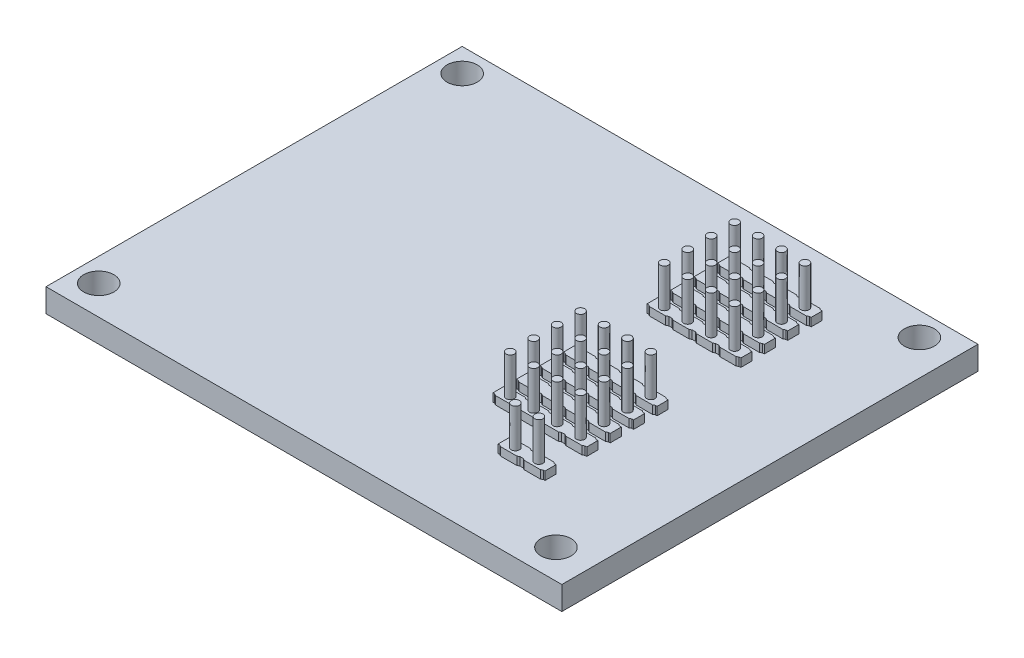
from build123d import *

# Parameters (mm, degrees)
SKETCH1_W                  = 55.88
SKETCH1_H                  = 45.085
BOSS_EXTRUDE1_DEPTH        = 2.54
F_4_CLEARANCE_HOLE1_D      = 3.2639
F_4_CLEARANCE_HOLE1_DEPTH  = 2.54
SKETCH4_R                  = 0.4445
CUT_EXTRUDE1_DEPTH         = 3.54
LPATTERN1_COUNT            = 4
LPATTERN1_PITCH            = 2.54
LPATTERN1_COUNT_DIR2       = 4
LPATTERN1_PITCH_DIR2       = 2.54
SKETCH5_R                  = 0.4445
CUT_EXTRUDE2_DEPTH         = 3.54
SKETCH6_W                  = 1.758187998
SKETCH6_H                  = 1.44539188
SKETCH6_R                  = 0.4445
BOSS_EXTRUDE2_DEPTH        = 0.889
LPATTERN3_COUNT            = 4
LPATTERN3_PITCH            = 2.54
LPATTERN3_COUNT_DIR2       = 4
LPATTERN3_PITCH_DIR2       = 2.54
LPATTERN4_COUNT            = 2
LPATTERN4_PITCH            = 16.6878
LPATTERN5_COPY_1_SKETCH_W  = 1.758187998
LPATTERN5_COPY_1_SKETCH_H  = 1.44539188
LPATTERN5_COPY_1_SKETCH_R  = 0.4445
LPATTERN5_COPY_1_DEPTH     = 0.889
LPATTERN5_COPY_2_SKETCH_W  = 1.758187998
LPATTERN5_COPY_2_SKETCH_H  = 1.44539188
LPATTERN5_COPY_2_SKETCH_R  = 0.4445
LPATTERN5_COPY_2_DEPTH     = 0.889
LPATTERN5_COPY_3_SKETCH_W  = 1.758187998
LPATTERN5_COPY_3_SKETCH_H  = 1.44539188
LPATTERN5_COPY_3_SKETCH_R  = 0.4445
LPATTERN5_COPY_3_DEPTH     = 0.889
LPATTERN5_COPY_4_SKETCH_W  = 1.758187998
LPATTERN5_COPY_4_SKETCH_H  = 1.44539188
LPATTERN5_COPY_4_SKETCH_R  = 0.4445
LPATTERN5_COPY_4_DEPTH     = 0.889
LPATTERN5_COPY_5_SKETCH_W  = 1.758187998
LPATTERN5_COPY_5_SKETCH_H  = 1.44539188
LPATTERN5_COPY_5_SKETCH_R  = 0.4445
LPATTERN5_COPY_5_DEPTH     = 0.889
LPATTERN5_COPY_6_SKETCH_W  = 1.758187998
LPATTERN5_COPY_6_SKETCH_H  = 1.44539188
LPATTERN5_COPY_6_SKETCH_R  = 0.4445
LPATTERN5_COPY_6_DEPTH     = 0.889
LPATTERN5_COPY_7_SKETCH_W  = 1.758187998
LPATTERN5_COPY_7_SKETCH_H  = 1.44539188
LPATTERN5_COPY_7_SKETCH_R  = 0.4445
LPATTERN5_COPY_7_DEPTH     = 0.889
LPATTERN5_COPY_8_SKETCH_W  = 1.758187998
LPATTERN5_COPY_8_SKETCH_H  = 1.44539188
LPATTERN5_COPY_8_SKETCH_R  = 0.4445
LPATTERN5_COPY_8_DEPTH     = 0.889
LPATTERN5_COPY_9_SKETCH_W  = 1.758187998
LPATTERN5_COPY_9_SKETCH_H  = 1.44539188
LPATTERN5_COPY_9_SKETCH_R  = 0.4445
LPATTERN5_COPY_9_DEPTH     = 0.889
LPATTERN5_COPY_10_SKETCH_W = 1.758187998
LPATTERN5_COPY_10_SKETCH_H = 1.44539188
LPATTERN5_COPY_10_SKETCH_R = 0.4445
LPATTERN5_COPY_10_DEPTH    = 0.889
LPATTERN5_COPY_11_SKETCH_W = 1.758187998
LPATTERN5_COPY_11_SKETCH_H = 1.44539188
LPATTERN5_COPY_11_SKETCH_R = 0.4445
LPATTERN5_COPY_11_DEPTH    = 0.889
LPATTERN5_COPY_12_SKETCH_W = 1.758187998
LPATTERN5_COPY_12_SKETCH_H = 1.44539188
LPATTERN5_COPY_12_SKETCH_R = 0.4445
LPATTERN5_COPY_12_DEPTH    = 0.889
LPATTERN5_COPY_13_SKETCH_W = 1.758187998
LPATTERN5_COPY_13_SKETCH_H = 1.44539188
LPATTERN5_COPY_13_SKETCH_R = 0.4445
LPATTERN5_COPY_13_DEPTH    = 0.889
LPATTERN5_COPY_14_SKETCH_W = 1.758187998
LPATTERN5_COPY_14_SKETCH_H = 1.44539188
LPATTERN5_COPY_14_SKETCH_R = 0.4445
LPATTERN5_COPY_14_DEPTH    = 0.889
LPATTERN5_COPY_15_SKETCH_W = 1.758187998
LPATTERN5_COPY_15_SKETCH_H = 1.44539188
LPATTERN5_COPY_15_SKETCH_R = 0.4445
LPATTERN5_COPY_15_DEPTH    = 0.889
LPATTERN5_COPY_16_SKETCH_W = 1.758187998
LPATTERN5_COPY_16_SKETCH_H = 1.44539188
LPATTERN5_COPY_16_SKETCH_R = 0.4445
LPATTERN5_COPY_16_DEPTH    = 0.889
LPATTERN5_COPY_17_SKETCH_W = 1.758187998
LPATTERN5_COPY_17_SKETCH_H = 1.44539188
LPATTERN5_COPY_17_SKETCH_R = 0.4445
LPATTERN5_COPY_17_DEPTH    = 0.889
LPATTERN5_COPY_18_SKETCH_W = 1.758187998
LPATTERN5_COPY_18_SKETCH_H = 1.44539188
LPATTERN5_COPY_18_SKETCH_R = 0.4445
LPATTERN5_COPY_18_DEPTH    = 0.889
LPATTERN5_COPY_19_SKETCH_W = 1.758187998
LPATTERN5_COPY_19_SKETCH_H = 1.44539188
LPATTERN5_COPY_19_SKETCH_R = 0.4445
LPATTERN5_COPY_19_DEPTH    = 0.889
LPATTERN5_COPY_20_SKETCH_W = 1.758187998
LPATTERN5_COPY_20_SKETCH_H = 1.44539188
LPATTERN5_COPY_20_SKETCH_R = 0.4445
LPATTERN5_COPY_20_DEPTH    = 0.889
LPATTERN5_COPY_21_SKETCH_W = 1.758187998
LPATTERN5_COPY_21_SKETCH_H = 1.44539188
LPATTERN5_COPY_21_SKETCH_R = 0.4445
LPATTERN5_COPY_21_DEPTH    = 0.889
LPATTERN5_COPY_22_SKETCH_W = 1.758187998
LPATTERN5_COPY_22_SKETCH_H = 1.44539188
LPATTERN5_COPY_22_SKETCH_R = 0.4445
LPATTERN5_COPY_22_DEPTH    = 0.889
LPATTERN5_COPY_23_SKETCH_W = 1.758187998
LPATTERN5_COPY_23_SKETCH_H = 1.44539188
LPATTERN5_COPY_23_SKETCH_R = 0.4445
LPATTERN5_COPY_23_DEPTH    = 0.889
LPATTERN5_COPY_24_SKETCH_W = 1.758187998
LPATTERN5_COPY_24_SKETCH_H = 1.44539188
LPATTERN5_COPY_24_SKETCH_R = 0.4445
LPATTERN5_COPY_24_DEPTH    = 0.889
LPATTERN5_COPY_25_SKETCH_W = 1.758187998
LPATTERN5_COPY_25_SKETCH_H = 1.44539188
LPATTERN5_COPY_25_SKETCH_R = 0.4445
LPATTERN5_COPY_25_DEPTH    = 0.889
LPATTERN5_COPY_26_SKETCH_W = 1.758187998
LPATTERN5_COPY_26_SKETCH_H = 1.44539188
LPATTERN5_COPY_26_SKETCH_R = 0.4445
LPATTERN5_COPY_26_DEPTH    = 0.889
LPATTERN5_COPY_27_SKETCH_W = 1.758187998
LPATTERN5_COPY_27_SKETCH_H = 1.44539188
LPATTERN5_COPY_27_SKETCH_R = 0.4445
LPATTERN5_COPY_27_DEPTH    = 0.889
LPATTERN5_COPY_28_SKETCH_W = 1.758187998
LPATTERN5_COPY_28_SKETCH_H = 1.44539188
LPATTERN5_COPY_28_SKETCH_R = 0.4445
LPATTERN5_COPY_28_DEPTH    = 0.889
LPATTERN5_COPY_29_SKETCH_W = 1.758187998
LPATTERN5_COPY_29_SKETCH_H = 1.44539188
LPATTERN5_COPY_29_SKETCH_R = 0.4445
LPATTERN5_COPY_29_DEPTH    = 0.889
LPATTERN5_COPY_30_SKETCH_W = 1.758187998
LPATTERN5_COPY_30_SKETCH_H = 1.44539188
LPATTERN5_COPY_30_SKETCH_R = 0.4445
LPATTERN5_COPY_30_DEPTH    = 0.889
LPATTERN6_COUNT            = 2
LPATTERN6_PITCH            = 28.829
LPATTERN7_COPY_1_SKETCH_W  = 1.758187998
LPATTERN7_COPY_1_SKETCH_H  = 1.44539188
LPATTERN7_COPY_1_SKETCH_R  = 0.4445
LPATTERN7_COPY_1_DEPTH     = 0.889
LPATTERN7_COPY_2_SKETCH_W  = 1.758187998
LPATTERN7_COPY_2_SKETCH_H  = 1.44539188
LPATTERN7_COPY_2_SKETCH_R  = 0.4445
LPATTERN7_COPY_2_DEPTH     = 0.889
SKETCH7_R                  = 0.4445
BOSS_EXTRUDE3_DEPTH        = 5.08
BOSS_EXTRUDE3_DEPTH_BACK   = 5.08


with BuildPart() as part:
    # Sketch1 → Boss-Extrude1 (new body)
    with BuildSketch(Plane(origin=(0, 0, 0), x_dir=(1, 0, 0), z_dir=(0, 1, 0))):
        Rectangle(SKETCH1_W, SKETCH1_H)
    extrude(amount=BOSS_EXTRUDE1_DEPTH)

    # #4 Clearance Hole1
    with Locations(Plane(origin=(0, 2.54, 0), x_dir=(1, 0, 0), z_dir=(0, 1, 0))):
        with Locations((-25.4, -19.3675), (-25.4, 20.0025), (24.13, 20.0025), (24.13, -19.3675)):
            Hole(F_4_CLEARANCE_HOLE1_D / 2, depth=F_4_CLEARANCE_HOLE1_DEPTH)

    # Sketch4 → Cut-Extrude1 (cut, through all)
    with BuildSketch(Plane(origin=(0, 2.54, 0), x_dir=(1, 0, 0), z_dir=(0, 1, 0))):
        with Locations((16.002, 15.7353)):
            Circle(SKETCH4_R)
        with Locations((16.002, -0.9525)):
            Circle(SKETCH4_R)
    cut_extrude1 = extrude(amount=-CUT_EXTRUDE1_DEPTH, mode=Mode.SUBTRACT)

    # LPattern1: Cut-Extrude1 4 × 4
    with Locations(*[(-j * LPATTERN1_PITCH_DIR2, 0, i * LPATTERN1_PITCH) for i in range(LPATTERN1_COUNT) for j in range(LPATTERN1_COUNT_DIR2) if (i, j) != (0, 0)]):
        add(cut_extrude1, mode=Mode.SUBTRACT)

    # Sketch5 → Cut-Extrude2 (cut, through all)
    with BuildSketch(Plane(origin=(0, 2.54, 0), x_dir=(1, 0, 0), z_dir=(0, 1, 0))):
        with Locations((16.002, -13.084491253)):
            Circle(SKETCH5_R)
        with Locations((13.462, -13.084491253)):
            Circle(SKETCH5_R)
    extrude(amount=-CUT_EXTRUDE2_DEPTH, mode=Mode.SUBTRACT)

    # Sketch6 → Boss-Extrude2 (add)
    with BuildSketch(Plane(origin=(0, 2.54, 0), x_dir=(1, 0, 0), z_dir=(0, 1, 0))):
        Polygon((17.085979817, 16.334198582), (17.272, 16.334198582), (17.272, 15.136401418), (17.085979817, 15.136401418), (16.881093999, 15.01260406), (16.881093999, 16.45799594), align=None)
        with Locations((16.002, 15.7353)):
            Rectangle(SKETCH6_W, SKETCH6_H)
        with Locations((16.002, 15.7353)):
            Circle(SKETCH6_R, mode=Mode.SUBTRACT)
        Polygon((14.732, 15.136401418), (14.918020183, 15.136401418), (15.122906001, 15.01260406), (15.122906001, 16.45799594), (14.918020183, 16.334198582), (14.732, 16.334198582), align=None)
    boss_extrude2 = extrude(amount=BOSS_EXTRUDE2_DEPTH)

    # LPattern3: Boss-Extrude2 4 × 4
    with Locations(*[(-j * LPATTERN3_PITCH_DIR2, 0, i * LPATTERN3_PITCH) for i in range(LPATTERN3_COUNT) for j in range(LPATTERN3_COUNT_DIR2) if (i, j) != (0, 0)]):
        add(boss_extrude2)

    # LPattern4: Boss-Extrude2 ×2
    with Locations(*[(0, 0, i * LPATTERN4_PITCH) for i in range(1, LPATTERN4_COUNT)]):
        add(boss_extrude2)

    # LPattern5 copy 1 sketch → LPattern5 copy 1 (add)
    with BuildSketch(Plane(origin=(-2.54, 2.54, 16.6878), x_dir=(1, 0, 0), z_dir=(0, 1, 0))):
        Polygon((17.085979817, 16.334198582), (17.272, 16.334198582), (17.272, 15.136401418), (17.085979817, 15.136401418), (16.881093999, 15.01260406), (16.881093999, 16.45799594), align=None)
        with Locations((16.002, 15.7353)):
            Rectangle(LPATTERN5_COPY_1_SKETCH_W, LPATTERN5_COPY_1_SKETCH_H)
        with Locations((16.002, 15.7353)):
            Circle(LPATTERN5_COPY_1_SKETCH_R, mode=Mode.SUBTRACT)
        Polygon((14.732, 15.136401418), (14.918020183, 15.136401418), (15.122906001, 15.01260406), (15.122906001, 16.45799594), (14.918020183, 16.334198582), (14.732, 16.334198582), align=None)
    extrude(amount=LPATTERN5_COPY_1_DEPTH)

    # LPattern5 copy 2 sketch → LPattern5 copy 2 (add)
    with BuildSketch(Plane(origin=(-5.08, 2.54, 16.6878), x_dir=(1, 0, 0), z_dir=(0, 1, 0))):
        Polygon((17.085979817, 16.334198582), (17.272, 16.334198582), (17.272, 15.136401418), (17.085979817, 15.136401418), (16.881093999, 15.01260406), (16.881093999, 16.45799594), align=None)
        with Locations((16.002, 15.7353)):
            Rectangle(LPATTERN5_COPY_2_SKETCH_W, LPATTERN5_COPY_2_SKETCH_H)
        with Locations((16.002, 15.7353)):
            Circle(LPATTERN5_COPY_2_SKETCH_R, mode=Mode.SUBTRACT)
        Polygon((14.732, 15.136401418), (14.918020183, 15.136401418), (15.122906001, 15.01260406), (15.122906001, 16.45799594), (14.918020183, 16.334198582), (14.732, 16.334198582), align=None)
    extrude(amount=LPATTERN5_COPY_2_DEPTH)

    # LPattern5 copy 3 sketch → LPattern5 copy 3 (add)
    with BuildSketch(Plane(origin=(-7.62, 2.54, 16.6878), x_dir=(1, 0, 0), z_dir=(0, 1, 0))):
        Polygon((17.085979817, 16.334198582), (17.272, 16.334198582), (17.272, 15.136401418), (17.085979817, 15.136401418), (16.881093999, 15.01260406), (16.881093999, 16.45799594), align=None)
        with Locations((16.002, 15.7353)):
            Rectangle(LPATTERN5_COPY_3_SKETCH_W, LPATTERN5_COPY_3_SKETCH_H)
        with Locations((16.002, 15.7353)):
            Circle(LPATTERN5_COPY_3_SKETCH_R, mode=Mode.SUBTRACT)
        Polygon((14.732, 15.136401418), (14.918020183, 15.136401418), (15.122906001, 15.01260406), (15.122906001, 16.45799594), (14.918020183, 16.334198582), (14.732, 16.334198582), align=None)
    extrude(amount=LPATTERN5_COPY_3_DEPTH)

    # LPattern5 copy 4 sketch → LPattern5 copy 4 (add)
    with BuildSketch(Plane(origin=(0, 2.54, 19.2278), x_dir=(1, 0, 0), z_dir=(0, 1, 0))):
        Polygon((17.085979817, 16.334198582), (17.272, 16.334198582), (17.272, 15.136401418), (17.085979817, 15.136401418), (16.881093999, 15.01260406), (16.881093999, 16.45799594), align=None)
        with Locations((16.002, 15.7353)):
            Rectangle(LPATTERN5_COPY_4_SKETCH_W, LPATTERN5_COPY_4_SKETCH_H)
        with Locations((16.002, 15.7353)):
            Circle(LPATTERN5_COPY_4_SKETCH_R, mode=Mode.SUBTRACT)
        Polygon((14.732, 15.136401418), (14.918020183, 15.136401418), (15.122906001, 15.01260406), (15.122906001, 16.45799594), (14.918020183, 16.334198582), (14.732, 16.334198582), align=None)
    extrude(amount=LPATTERN5_COPY_4_DEPTH)

    # LPattern5 copy 5 sketch → LPattern5 copy 5 (add)
    with BuildSketch(Plane(origin=(-2.54, 2.54, 19.2278), x_dir=(1, 0, 0), z_dir=(0, 1, 0))):
        Polygon((17.085979817, 16.334198582), (17.272, 16.334198582), (17.272, 15.136401418), (17.085979817, 15.136401418), (16.881093999, 15.01260406), (16.881093999, 16.45799594), align=None)
        with Locations((16.002, 15.7353)):
            Rectangle(LPATTERN5_COPY_5_SKETCH_W, LPATTERN5_COPY_5_SKETCH_H)
        with Locations((16.002, 15.7353)):
            Circle(LPATTERN5_COPY_5_SKETCH_R, mode=Mode.SUBTRACT)
        Polygon((14.732, 15.136401418), (14.918020183, 15.136401418), (15.122906001, 15.01260406), (15.122906001, 16.45799594), (14.918020183, 16.334198582), (14.732, 16.334198582), align=None)
    extrude(amount=LPATTERN5_COPY_5_DEPTH)

    # LPattern5 copy 6 sketch → LPattern5 copy 6 (add)
    with BuildSketch(Plane(origin=(-5.08, 2.54, 19.2278), x_dir=(1, 0, 0), z_dir=(0, 1, 0))):
        Polygon((17.085979817, 16.334198582), (17.272, 16.334198582), (17.272, 15.136401418), (17.085979817, 15.136401418), (16.881093999, 15.01260406), (16.881093999, 16.45799594), align=None)
        with Locations((16.002, 15.7353)):
            Rectangle(LPATTERN5_COPY_6_SKETCH_W, LPATTERN5_COPY_6_SKETCH_H)
        with Locations((16.002, 15.7353)):
            Circle(LPATTERN5_COPY_6_SKETCH_R, mode=Mode.SUBTRACT)
        Polygon((14.732, 15.136401418), (14.918020183, 15.136401418), (15.122906001, 15.01260406), (15.122906001, 16.45799594), (14.918020183, 16.334198582), (14.732, 16.334198582), align=None)
    extrude(amount=LPATTERN5_COPY_6_DEPTH)

    # LPattern5 copy 7 sketch → LPattern5 copy 7 (add)
    with BuildSketch(Plane(origin=(-7.62, 2.54, 19.2278), x_dir=(1, 0, 0), z_dir=(0, 1, 0))):
        Polygon((17.085979817, 16.334198582), (17.272, 16.334198582), (17.272, 15.136401418), (17.085979817, 15.136401418), (16.881093999, 15.01260406), (16.881093999, 16.45799594), align=None)
        with Locations((16.002, 15.7353)):
            Rectangle(LPATTERN5_COPY_7_SKETCH_W, LPATTERN5_COPY_7_SKETCH_H)
        with Locations((16.002, 15.7353)):
            Circle(LPATTERN5_COPY_7_SKETCH_R, mode=Mode.SUBTRACT)
        Polygon((14.732, 15.136401418), (14.918020183, 15.136401418), (15.122906001, 15.01260406), (15.122906001, 16.45799594), (14.918020183, 16.334198582), (14.732, 16.334198582), align=None)
    extrude(amount=LPATTERN5_COPY_7_DEPTH)

    # LPattern5 copy 8 sketch → LPattern5 copy 8 (add)
    with BuildSketch(Plane(origin=(0, 2.54, 21.7678), x_dir=(1, 0, 0), z_dir=(0, 1, 0))):
        Polygon((17.085979817, 16.334198582), (17.272, 16.334198582), (17.272, 15.136401418), (17.085979817, 15.136401418), (16.881093999, 15.01260406), (16.881093999, 16.45799594), align=None)
        with Locations((16.002, 15.7353)):
            Rectangle(LPATTERN5_COPY_8_SKETCH_W, LPATTERN5_COPY_8_SKETCH_H)
        with Locations((16.002, 15.7353)):
            Circle(LPATTERN5_COPY_8_SKETCH_R, mode=Mode.SUBTRACT)
        Polygon((14.732, 15.136401418), (14.918020183, 15.136401418), (15.122906001, 15.01260406), (15.122906001, 16.45799594), (14.918020183, 16.334198582), (14.732, 16.334198582), align=None)
    extrude(amount=LPATTERN5_COPY_8_DEPTH)

    # LPattern5 copy 9 sketch → LPattern5 copy 9 (add)
    with BuildSketch(Plane(origin=(-2.54, 2.54, 21.7678), x_dir=(1, 0, 0), z_dir=(0, 1, 0))):
        Polygon((17.085979817, 16.334198582), (17.272, 16.334198582), (17.272, 15.136401418), (17.085979817, 15.136401418), (16.881093999, 15.01260406), (16.881093999, 16.45799594), align=None)
        with Locations((16.002, 15.7353)):
            Rectangle(LPATTERN5_COPY_9_SKETCH_W, LPATTERN5_COPY_9_SKETCH_H)
        with Locations((16.002, 15.7353)):
            Circle(LPATTERN5_COPY_9_SKETCH_R, mode=Mode.SUBTRACT)
        Polygon((14.732, 15.136401418), (14.918020183, 15.136401418), (15.122906001, 15.01260406), (15.122906001, 16.45799594), (14.918020183, 16.334198582), (14.732, 16.334198582), align=None)
    extrude(amount=LPATTERN5_COPY_9_DEPTH)

    # LPattern5 copy 10 sketch → LPattern5 copy 10 (add)
    with BuildSketch(Plane(origin=(-5.08, 2.54, 21.7678), x_dir=(1, 0, 0), z_dir=(0, 1, 0))):
        Polygon((17.085979817, 16.334198582), (17.272, 16.334198582), (17.272, 15.136401418), (17.085979817, 15.136401418), (16.881093999, 15.01260406), (16.881093999, 16.45799594), align=None)
        with Locations((16.002, 15.7353)):
            Rectangle(LPATTERN5_COPY_10_SKETCH_W, LPATTERN5_COPY_10_SKETCH_H)
        with Locations((16.002, 15.7353)):
            Circle(LPATTERN5_COPY_10_SKETCH_R, mode=Mode.SUBTRACT)
        Polygon((14.732, 15.136401418), (14.918020183, 15.136401418), (15.122906001, 15.01260406), (15.122906001, 16.45799594), (14.918020183, 16.334198582), (14.732, 16.334198582), align=None)
    extrude(amount=LPATTERN5_COPY_10_DEPTH)

    # LPattern5 copy 11 sketch → LPattern5 copy 11 (add)
    with BuildSketch(Plane(origin=(-7.62, 2.54, 21.7678), x_dir=(1, 0, 0), z_dir=(0, 1, 0))):
        Polygon((17.085979817, 16.334198582), (17.272, 16.334198582), (17.272, 15.136401418), (17.085979817, 15.136401418), (16.881093999, 15.01260406), (16.881093999, 16.45799594), align=None)
        with Locations((16.002, 15.7353)):
            Rectangle(LPATTERN5_COPY_11_SKETCH_W, LPATTERN5_COPY_11_SKETCH_H)
        with Locations((16.002, 15.7353)):
            Circle(LPATTERN5_COPY_11_SKETCH_R, mode=Mode.SUBTRACT)
        Polygon((14.732, 15.136401418), (14.918020183, 15.136401418), (15.122906001, 15.01260406), (15.122906001, 16.45799594), (14.918020183, 16.334198582), (14.732, 16.334198582), align=None)
    extrude(amount=LPATTERN5_COPY_11_DEPTH)

    # LPattern5 copy 12 sketch → LPattern5 copy 12 (add)
    with BuildSketch(Plane(origin=(0, 2.54, 24.3078), x_dir=(1, 0, 0), z_dir=(0, 1, 0))):
        Polygon((17.085979817, 16.334198582), (17.272, 16.334198582), (17.272, 15.136401418), (17.085979817, 15.136401418), (16.881093999, 15.01260406), (16.881093999, 16.45799594), align=None)
        with Locations((16.002, 15.7353)):
            Rectangle(LPATTERN5_COPY_12_SKETCH_W, LPATTERN5_COPY_12_SKETCH_H)
        with Locations((16.002, 15.7353)):
            Circle(LPATTERN5_COPY_12_SKETCH_R, mode=Mode.SUBTRACT)
        Polygon((14.732, 15.136401418), (14.918020183, 15.136401418), (15.122906001, 15.01260406), (15.122906001, 16.45799594), (14.918020183, 16.334198582), (14.732, 16.334198582), align=None)
    extrude(amount=LPATTERN5_COPY_12_DEPTH)

    # LPattern5 copy 13 sketch → LPattern5 copy 13 (add)
    with BuildSketch(Plane(origin=(-2.54, 2.54, 24.3078), x_dir=(1, 0, 0), z_dir=(0, 1, 0))):
        Polygon((17.085979817, 16.334198582), (17.272, 16.334198582), (17.272, 15.136401418), (17.085979817, 15.136401418), (16.881093999, 15.01260406), (16.881093999, 16.45799594), align=None)
        with Locations((16.002, 15.7353)):
            Rectangle(LPATTERN5_COPY_13_SKETCH_W, LPATTERN5_COPY_13_SKETCH_H)
        with Locations((16.002, 15.7353)):
            Circle(LPATTERN5_COPY_13_SKETCH_R, mode=Mode.SUBTRACT)
        Polygon((14.732, 15.136401418), (14.918020183, 15.136401418), (15.122906001, 15.01260406), (15.122906001, 16.45799594), (14.918020183, 16.334198582), (14.732, 16.334198582), align=None)
    extrude(amount=LPATTERN5_COPY_13_DEPTH)

    # LPattern5 copy 14 sketch → LPattern5 copy 14 (add)
    with BuildSketch(Plane(origin=(-5.08, 2.54, 24.3078), x_dir=(1, 0, 0), z_dir=(0, 1, 0))):
        Polygon((17.085979817, 16.334198582), (17.272, 16.334198582), (17.272, 15.136401418), (17.085979817, 15.136401418), (16.881093999, 15.01260406), (16.881093999, 16.45799594), align=None)
        with Locations((16.002, 15.7353)):
            Rectangle(LPATTERN5_COPY_14_SKETCH_W, LPATTERN5_COPY_14_SKETCH_H)
        with Locations((16.002, 15.7353)):
            Circle(LPATTERN5_COPY_14_SKETCH_R, mode=Mode.SUBTRACT)
        Polygon((14.732, 15.136401418), (14.918020183, 15.136401418), (15.122906001, 15.01260406), (15.122906001, 16.45799594), (14.918020183, 16.334198582), (14.732, 16.334198582), align=None)
    extrude(amount=LPATTERN5_COPY_14_DEPTH)

    # LPattern5 copy 15 sketch → LPattern5 copy 15 (add)
    with BuildSketch(Plane(origin=(-7.62, 2.54, 24.3078), x_dir=(1, 0, 0), z_dir=(0, 1, 0))):
        Polygon((17.085979817, 16.334198582), (17.272, 16.334198582), (17.272, 15.136401418), (17.085979817, 15.136401418), (16.881093999, 15.01260406), (16.881093999, 16.45799594), align=None)
        with Locations((16.002, 15.7353)):
            Rectangle(LPATTERN5_COPY_15_SKETCH_W, LPATTERN5_COPY_15_SKETCH_H)
        with Locations((16.002, 15.7353)):
            Circle(LPATTERN5_COPY_15_SKETCH_R, mode=Mode.SUBTRACT)
        Polygon((14.732, 15.136401418), (14.918020183, 15.136401418), (15.122906001, 15.01260406), (15.122906001, 16.45799594), (14.918020183, 16.334198582), (14.732, 16.334198582), align=None)
    extrude(amount=LPATTERN5_COPY_15_DEPTH)

    # LPattern5 copy 16 sketch → LPattern5 copy 16 (add)
    with BuildSketch(Plane(origin=(-2.54, 2.54, 0), x_dir=(1, 0, 0), z_dir=(0, 1, 0))):
        Polygon((17.085979817, 16.334198582), (17.272, 16.334198582), (17.272, 15.136401418), (17.085979817, 15.136401418), (16.881093999, 15.01260406), (16.881093999, 16.45799594), align=None)
        with Locations((16.002, 15.7353)):
            Rectangle(LPATTERN5_COPY_16_SKETCH_W, LPATTERN5_COPY_16_SKETCH_H)
        with Locations((16.002, 15.7353)):
            Circle(LPATTERN5_COPY_16_SKETCH_R, mode=Mode.SUBTRACT)
        Polygon((14.732, 15.136401418), (14.918020183, 15.136401418), (15.122906001, 15.01260406), (15.122906001, 16.45799594), (14.918020183, 16.334198582), (14.732, 16.334198582), align=None)
    extrude(amount=LPATTERN5_COPY_16_DEPTH)

    # LPattern5 copy 17 sketch → LPattern5 copy 17 (add)
    with BuildSketch(Plane(origin=(-5.08, 2.54, 0), x_dir=(1, 0, 0), z_dir=(0, 1, 0))):
        Polygon((17.085979817, 16.334198582), (17.272, 16.334198582), (17.272, 15.136401418), (17.085979817, 15.136401418), (16.881093999, 15.01260406), (16.881093999, 16.45799594), align=None)
        with Locations((16.002, 15.7353)):
            Rectangle(LPATTERN5_COPY_17_SKETCH_W, LPATTERN5_COPY_17_SKETCH_H)
        with Locations((16.002, 15.7353)):
            Circle(LPATTERN5_COPY_17_SKETCH_R, mode=Mode.SUBTRACT)
        Polygon((14.732, 15.136401418), (14.918020183, 15.136401418), (15.122906001, 15.01260406), (15.122906001, 16.45799594), (14.918020183, 16.334198582), (14.732, 16.334198582), align=None)
    extrude(amount=LPATTERN5_COPY_17_DEPTH)

    # LPattern5 copy 18 sketch → LPattern5 copy 18 (add)
    with BuildSketch(Plane(origin=(-7.62, 2.54, 0), x_dir=(1, 0, 0), z_dir=(0, 1, 0))):
        Polygon((17.085979817, 16.334198582), (17.272, 16.334198582), (17.272, 15.136401418), (17.085979817, 15.136401418), (16.881093999, 15.01260406), (16.881093999, 16.45799594), align=None)
        with Locations((16.002, 15.7353)):
            Rectangle(LPATTERN5_COPY_18_SKETCH_W, LPATTERN5_COPY_18_SKETCH_H)
        with Locations((16.002, 15.7353)):
            Circle(LPATTERN5_COPY_18_SKETCH_R, mode=Mode.SUBTRACT)
        Polygon((14.732, 15.136401418), (14.918020183, 15.136401418), (15.122906001, 15.01260406), (15.122906001, 16.45799594), (14.918020183, 16.334198582), (14.732, 16.334198582), align=None)
    extrude(amount=LPATTERN5_COPY_18_DEPTH)

    # LPattern5 copy 19 sketch → LPattern5 copy 19 (add)
    with BuildSketch(Plane(origin=(0, 2.54, 2.54), x_dir=(1, 0, 0), z_dir=(0, 1, 0))):
        Polygon((17.085979817, 16.334198582), (17.272, 16.334198582), (17.272, 15.136401418), (17.085979817, 15.136401418), (16.881093999, 15.01260406), (16.881093999, 16.45799594), align=None)
        with Locations((16.002, 15.7353)):
            Rectangle(LPATTERN5_COPY_19_SKETCH_W, LPATTERN5_COPY_19_SKETCH_H)
        with Locations((16.002, 15.7353)):
            Circle(LPATTERN5_COPY_19_SKETCH_R, mode=Mode.SUBTRACT)
        Polygon((14.732, 15.136401418), (14.918020183, 15.136401418), (15.122906001, 15.01260406), (15.122906001, 16.45799594), (14.918020183, 16.334198582), (14.732, 16.334198582), align=None)
    extrude(amount=LPATTERN5_COPY_19_DEPTH)

    # LPattern5 copy 20 sketch → LPattern5 copy 20 (add)
    with BuildSketch(Plane(origin=(-2.54, 2.54, 2.54), x_dir=(1, 0, 0), z_dir=(0, 1, 0))):
        Polygon((17.085979817, 16.334198582), (17.272, 16.334198582), (17.272, 15.136401418), (17.085979817, 15.136401418), (16.881093999, 15.01260406), (16.881093999, 16.45799594), align=None)
        with Locations((16.002, 15.7353)):
            Rectangle(LPATTERN5_COPY_20_SKETCH_W, LPATTERN5_COPY_20_SKETCH_H)
        with Locations((16.002, 15.7353)):
            Circle(LPATTERN5_COPY_20_SKETCH_R, mode=Mode.SUBTRACT)
        Polygon((14.732, 15.136401418), (14.918020183, 15.136401418), (15.122906001, 15.01260406), (15.122906001, 16.45799594), (14.918020183, 16.334198582), (14.732, 16.334198582), align=None)
    extrude(amount=LPATTERN5_COPY_20_DEPTH)

    # LPattern5 copy 21 sketch → LPattern5 copy 21 (add)
    with BuildSketch(Plane(origin=(-5.08, 2.54, 2.54), x_dir=(1, 0, 0), z_dir=(0, 1, 0))):
        Polygon((17.085979817, 16.334198582), (17.272, 16.334198582), (17.272, 15.136401418), (17.085979817, 15.136401418), (16.881093999, 15.01260406), (16.881093999, 16.45799594), align=None)
        with Locations((16.002, 15.7353)):
            Rectangle(LPATTERN5_COPY_21_SKETCH_W, LPATTERN5_COPY_21_SKETCH_H)
        with Locations((16.002, 15.7353)):
            Circle(LPATTERN5_COPY_21_SKETCH_R, mode=Mode.SUBTRACT)
        Polygon((14.732, 15.136401418), (14.918020183, 15.136401418), (15.122906001, 15.01260406), (15.122906001, 16.45799594), (14.918020183, 16.334198582), (14.732, 16.334198582), align=None)
    extrude(amount=LPATTERN5_COPY_21_DEPTH)

    # LPattern5 copy 22 sketch → LPattern5 copy 22 (add)
    with BuildSketch(Plane(origin=(-7.62, 2.54, 2.54), x_dir=(1, 0, 0), z_dir=(0, 1, 0))):
        Polygon((17.085979817, 16.334198582), (17.272, 16.334198582), (17.272, 15.136401418), (17.085979817, 15.136401418), (16.881093999, 15.01260406), (16.881093999, 16.45799594), align=None)
        with Locations((16.002, 15.7353)):
            Rectangle(LPATTERN5_COPY_22_SKETCH_W, LPATTERN5_COPY_22_SKETCH_H)
        with Locations((16.002, 15.7353)):
            Circle(LPATTERN5_COPY_22_SKETCH_R, mode=Mode.SUBTRACT)
        Polygon((14.732, 15.136401418), (14.918020183, 15.136401418), (15.122906001, 15.01260406), (15.122906001, 16.45799594), (14.918020183, 16.334198582), (14.732, 16.334198582), align=None)
    extrude(amount=LPATTERN5_COPY_22_DEPTH)

    # LPattern5 copy 23 sketch → LPattern5 copy 23 (add)
    with BuildSketch(Plane(origin=(0, 2.54, 5.08), x_dir=(1, 0, 0), z_dir=(0, 1, 0))):
        Polygon((17.085979817, 16.334198582), (17.272, 16.334198582), (17.272, 15.136401418), (17.085979817, 15.136401418), (16.881093999, 15.01260406), (16.881093999, 16.45799594), align=None)
        with Locations((16.002, 15.7353)):
            Rectangle(LPATTERN5_COPY_23_SKETCH_W, LPATTERN5_COPY_23_SKETCH_H)
        with Locations((16.002, 15.7353)):
            Circle(LPATTERN5_COPY_23_SKETCH_R, mode=Mode.SUBTRACT)
        Polygon((14.732, 15.136401418), (14.918020183, 15.136401418), (15.122906001, 15.01260406), (15.122906001, 16.45799594), (14.918020183, 16.334198582), (14.732, 16.334198582), align=None)
    extrude(amount=LPATTERN5_COPY_23_DEPTH)

    # LPattern5 copy 24 sketch → LPattern5 copy 24 (add)
    with BuildSketch(Plane(origin=(-2.54, 2.54, 5.08), x_dir=(1, 0, 0), z_dir=(0, 1, 0))):
        Polygon((17.085979817, 16.334198582), (17.272, 16.334198582), (17.272, 15.136401418), (17.085979817, 15.136401418), (16.881093999, 15.01260406), (16.881093999, 16.45799594), align=None)
        with Locations((16.002, 15.7353)):
            Rectangle(LPATTERN5_COPY_24_SKETCH_W, LPATTERN5_COPY_24_SKETCH_H)
        with Locations((16.002, 15.7353)):
            Circle(LPATTERN5_COPY_24_SKETCH_R, mode=Mode.SUBTRACT)
        Polygon((14.732, 15.136401418), (14.918020183, 15.136401418), (15.122906001, 15.01260406), (15.122906001, 16.45799594), (14.918020183, 16.334198582), (14.732, 16.334198582), align=None)
    extrude(amount=LPATTERN5_COPY_24_DEPTH)

    # LPattern5 copy 25 sketch → LPattern5 copy 25 (add)
    with BuildSketch(Plane(origin=(-5.08, 2.54, 5.08), x_dir=(1, 0, 0), z_dir=(0, 1, 0))):
        Polygon((17.085979817, 16.334198582), (17.272, 16.334198582), (17.272, 15.136401418), (17.085979817, 15.136401418), (16.881093999, 15.01260406), (16.881093999, 16.45799594), align=None)
        with Locations((16.002, 15.7353)):
            Rectangle(LPATTERN5_COPY_25_SKETCH_W, LPATTERN5_COPY_25_SKETCH_H)
        with Locations((16.002, 15.7353)):
            Circle(LPATTERN5_COPY_25_SKETCH_R, mode=Mode.SUBTRACT)
        Polygon((14.732, 15.136401418), (14.918020183, 15.136401418), (15.122906001, 15.01260406), (15.122906001, 16.45799594), (14.918020183, 16.334198582), (14.732, 16.334198582), align=None)
    extrude(amount=LPATTERN5_COPY_25_DEPTH)

    # LPattern5 copy 26 sketch → LPattern5 copy 26 (add)
    with BuildSketch(Plane(origin=(-7.62, 2.54, 5.08), x_dir=(1, 0, 0), z_dir=(0, 1, 0))):
        Polygon((17.085979817, 16.334198582), (17.272, 16.334198582), (17.272, 15.136401418), (17.085979817, 15.136401418), (16.881093999, 15.01260406), (16.881093999, 16.45799594), align=None)
        with Locations((16.002, 15.7353)):
            Rectangle(LPATTERN5_COPY_26_SKETCH_W, LPATTERN5_COPY_26_SKETCH_H)
        with Locations((16.002, 15.7353)):
            Circle(LPATTERN5_COPY_26_SKETCH_R, mode=Mode.SUBTRACT)
        Polygon((14.732, 15.136401418), (14.918020183, 15.136401418), (15.122906001, 15.01260406), (15.122906001, 16.45799594), (14.918020183, 16.334198582), (14.732, 16.334198582), align=None)
    extrude(amount=LPATTERN5_COPY_26_DEPTH)

    # LPattern5 copy 27 sketch → LPattern5 copy 27 (add)
    with BuildSketch(Plane(origin=(0, 2.54, 7.62), x_dir=(1, 0, 0), z_dir=(0, 1, 0))):
        Polygon((17.085979817, 16.334198582), (17.272, 16.334198582), (17.272, 15.136401418), (17.085979817, 15.136401418), (16.881093999, 15.01260406), (16.881093999, 16.45799594), align=None)
        with Locations((16.002, 15.7353)):
            Rectangle(LPATTERN5_COPY_27_SKETCH_W, LPATTERN5_COPY_27_SKETCH_H)
        with Locations((16.002, 15.7353)):
            Circle(LPATTERN5_COPY_27_SKETCH_R, mode=Mode.SUBTRACT)
        Polygon((14.732, 15.136401418), (14.918020183, 15.136401418), (15.122906001, 15.01260406), (15.122906001, 16.45799594), (14.918020183, 16.334198582), (14.732, 16.334198582), align=None)
    extrude(amount=LPATTERN5_COPY_27_DEPTH)

    # LPattern5 copy 28 sketch → LPattern5 copy 28 (add)
    with BuildSketch(Plane(origin=(-2.54, 2.54, 7.62), x_dir=(1, 0, 0), z_dir=(0, 1, 0))):
        Polygon((17.085979817, 16.334198582), (17.272, 16.334198582), (17.272, 15.136401418), (17.085979817, 15.136401418), (16.881093999, 15.01260406), (16.881093999, 16.45799594), align=None)
        with Locations((16.002, 15.7353)):
            Rectangle(LPATTERN5_COPY_28_SKETCH_W, LPATTERN5_COPY_28_SKETCH_H)
        with Locations((16.002, 15.7353)):
            Circle(LPATTERN5_COPY_28_SKETCH_R, mode=Mode.SUBTRACT)
        Polygon((14.732, 15.136401418), (14.918020183, 15.136401418), (15.122906001, 15.01260406), (15.122906001, 16.45799594), (14.918020183, 16.334198582), (14.732, 16.334198582), align=None)
    extrude(amount=LPATTERN5_COPY_28_DEPTH)

    # LPattern5 copy 29 sketch → LPattern5 copy 29 (add)
    with BuildSketch(Plane(origin=(-5.08, 2.54, 7.62), x_dir=(1, 0, 0), z_dir=(0, 1, 0))):
        Polygon((17.085979817, 16.334198582), (17.272, 16.334198582), (17.272, 15.136401418), (17.085979817, 15.136401418), (16.881093999, 15.01260406), (16.881093999, 16.45799594), align=None)
        with Locations((16.002, 15.7353)):
            Rectangle(LPATTERN5_COPY_29_SKETCH_W, LPATTERN5_COPY_29_SKETCH_H)
        with Locations((16.002, 15.7353)):
            Circle(LPATTERN5_COPY_29_SKETCH_R, mode=Mode.SUBTRACT)
        Polygon((14.732, 15.136401418), (14.918020183, 15.136401418), (15.122906001, 15.01260406), (15.122906001, 16.45799594), (14.918020183, 16.334198582), (14.732, 16.334198582), align=None)
    extrude(amount=LPATTERN5_COPY_29_DEPTH)

    # LPattern5 copy 30 sketch → LPattern5 copy 30 (add)
    with BuildSketch(Plane(origin=(-7.62, 2.54, 7.62), x_dir=(1, 0, 0), z_dir=(0, 1, 0))):
        Polygon((17.085979817, 16.334198582), (17.272, 16.334198582), (17.272, 15.136401418), (17.085979817, 15.136401418), (16.881093999, 15.01260406), (16.881093999, 16.45799594), align=None)
        with Locations((16.002, 15.7353)):
            Rectangle(LPATTERN5_COPY_30_SKETCH_W, LPATTERN5_COPY_30_SKETCH_H)
        with Locations((16.002, 15.7353)):
            Circle(LPATTERN5_COPY_30_SKETCH_R, mode=Mode.SUBTRACT)
        Polygon((14.732, 15.136401418), (14.918020183, 15.136401418), (15.122906001, 15.01260406), (15.122906001, 16.45799594), (14.918020183, 16.334198582), (14.732, 16.334198582), align=None)
    extrude(amount=LPATTERN5_COPY_30_DEPTH)

    # LPattern6: Boss-Extrude2 ×2
    with Locations(*[(0, 0, i * LPATTERN6_PITCH) for i in range(1, LPATTERN6_COUNT)]):
        add(boss_extrude2)

    # LPattern7 copy 1 sketch → LPattern7 copy 1 (add)
    with BuildSketch(Plane(origin=(-2.54, 2.54, 28.829), x_dir=(1, 0, 0), z_dir=(0, 1, 0))):
        Polygon((17.085979817, 16.334198582), (17.272, 16.334198582), (17.272, 15.136401418), (17.085979817, 15.136401418), (16.881093999, 15.01260406), (16.881093999, 16.45799594), align=None)
        with Locations((16.002, 15.7353)):
            Rectangle(LPATTERN7_COPY_1_SKETCH_W, LPATTERN7_COPY_1_SKETCH_H)
        with Locations((16.002, 15.7353)):
            Circle(LPATTERN7_COPY_1_SKETCH_R, mode=Mode.SUBTRACT)
        Polygon((14.732, 15.136401418), (14.918020183, 15.136401418), (15.122906001, 15.01260406), (15.122906001, 16.45799594), (14.918020183, 16.334198582), (14.732, 16.334198582), align=None)
    extrude(amount=LPATTERN7_COPY_1_DEPTH)

    # LPattern7 copy 2 sketch → LPattern7 copy 2 (add)
    with BuildSketch(Plane(origin=(-2.54, 2.54, 0), x_dir=(1, 0, 0), z_dir=(0, 1, 0))):
        Polygon((17.085979817, 16.334198582), (17.272, 16.334198582), (17.272, 15.136401418), (17.085979817, 15.136401418), (16.881093999, 15.01260406), (16.881093999, 16.45799594), align=None)
        with Locations((16.002, 15.7353)):
            Rectangle(LPATTERN7_COPY_2_SKETCH_W, LPATTERN7_COPY_2_SKETCH_H)
        with Locations((16.002, 15.7353)):
            Circle(LPATTERN7_COPY_2_SKETCH_R, mode=Mode.SUBTRACT)
        Polygon((14.732, 15.136401418), (14.918020183, 15.136401418), (15.122906001, 15.01260406), (15.122906001, 16.45799594), (14.918020183, 16.334198582), (14.732, 16.334198582), align=None)
    extrude(amount=LPATTERN7_COPY_2_DEPTH)

    # Sketch7 → Boss-Extrude3 (add, two sides)
    with BuildSketch(Plane(origin=(0, 2.54, 0), x_dir=(1, 0, 0), z_dir=(0, 1, 0))) as boss_extrude3_sk:
        with Locations((16.002, 15.7353)):
            Circle(SKETCH7_R)
        with Locations((13.462, 15.7353)):
            Circle(SKETCH7_R)
        with Locations((10.922, 15.7353)):
            Circle(SKETCH7_R)
        with Locations((8.382, 15.7353)):
            Circle(SKETCH7_R)
        with Locations((8.382, 13.1953)):
            Circle(SKETCH7_R)
        with Locations((10.922, 13.1953)):
            Circle(SKETCH7_R)
        with Locations((13.462, 13.1953)):
            Circle(SKETCH7_R)
        with Locations((16.002, 13.1953)):
            Circle(SKETCH7_R)
        with Locations((16.002, 10.6553)):
            Circle(SKETCH7_R)
        with Locations((13.462, 10.6553)):
            Circle(SKETCH7_R)
        with Locations((10.922, 10.6553)):
            Circle(SKETCH7_R)
        with Locations((8.382, 10.6553)):
            Circle(SKETCH7_R)
        with Locations((8.382, 8.1153)):
            Circle(SKETCH7_R)
        with Locations((10.922, 8.1153)):
            Circle(SKETCH7_R)
        with Locations((13.462, 8.1153)):
            Circle(SKETCH7_R)
        with Locations((16.002, 8.1153)):
            Circle(SKETCH7_R)
        with Locations((16.002, -0.9525)):
            Circle(SKETCH7_R)
        with Locations((16.002, -3.4925)):
            Circle(SKETCH7_R)
        with Locations((16.002, -6.0325)):
            Circle(SKETCH7_R)
        with Locations((16.002, -8.5725)):
            Circle(SKETCH7_R)
        with Locations((13.462, -0.9525)):
            Circle(SKETCH7_R)
        with Locations((13.462, -3.4925)):
            Circle(SKETCH7_R)
        with Locations((13.462, -6.0325)):
            Circle(SKETCH7_R)
        with Locations((13.462, -8.5725)):
            Circle(SKETCH7_R)
        with Locations((10.922, -8.5725)):
            Circle(SKETCH7_R)
        with Locations((10.922, -6.0325)):
            Circle(SKETCH7_R)
        with Locations((10.922, -3.4925)):
            Circle(SKETCH7_R)
        with Locations((10.922, -0.9525)):
            Circle(SKETCH7_R)
        with Locations((8.382, -0.9525)):
            Circle(SKETCH7_R)
        with Locations((8.382, -3.4925)):
            Circle(SKETCH7_R)
        with Locations((8.382, -6.0325)):
            Circle(SKETCH7_R)
        with Locations((8.382, -8.5725)):
            Circle(SKETCH7_R)
        with Locations((16.002, -13.0937)):
            Circle(SKETCH7_R)
        with Locations((13.462, -13.0937)):
            Circle(SKETCH7_R)
    extrude(amount=BOSS_EXTRUDE3_DEPTH)
    extrude(boss_extrude3_sk.sketch, amount=-BOSS_EXTRUDE3_DEPTH_BACK)


solid = part.part
